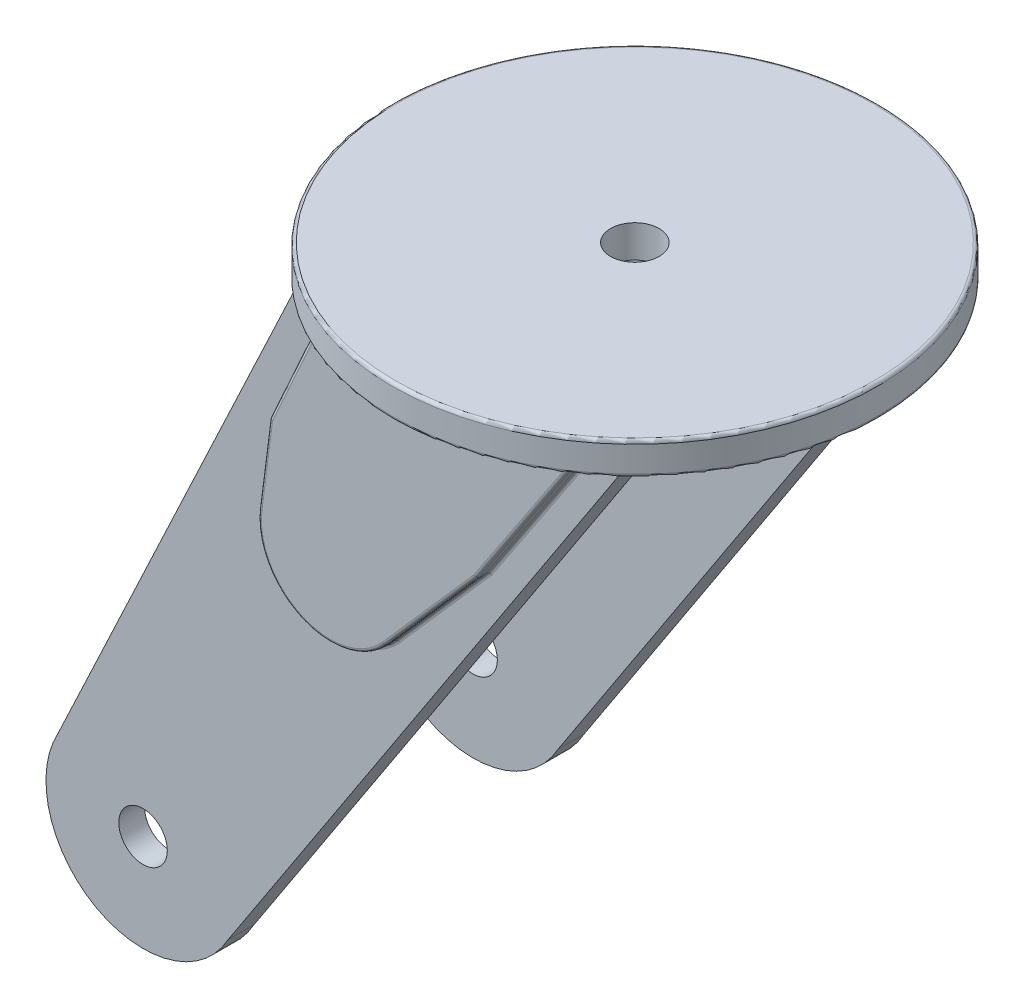
from build123d import *

# Parameters (mm, degrees)
SKETCH1_R            = 75
BOSS_EXTRUDE1_DEPTH  = 10
FILLET1_R            = 1
SKETCH2_R            = 7.5
BOSS_EXTRUDE2_DEPTH  = 8
BOSS_EXTRUDE3_DEPTH  = 4
FILLET2_R            = 1
CUT_EXTRUDE1_DEPTH   = 4
FILLET3_R            = 1
FILLET2_OF_MIRROR1_R = 1
FILLET3_OF_MIRROR1_R = 1
SKETCH7_R            = 7.5
CUT_EXTRUDE2_DEPTH   = 211


with BuildPart() as part:
    # Sketch1 → Boss-Extrude1 (new body)
    with BuildSketch(Plane(origin=(0, 0, 0), x_dir=(1, 0, 0), z_dir=(0, 1, 0))):
        Circle(SKETCH1_R)
    extrude(amount=BOSS_EXTRUDE1_DEPTH)

    # Fillet1
    fillet1_edges = [part.edges().sort_by_distance(p)[0] for p in [
        (-75, 0, 0),
        (-75, 10, 0),
    ]]
    fillet(fillet1_edges, radius=FILLET1_R)

    # Sketch2 → Boss-Extrude2 (add)
    with BuildSketch(Plane.XY.offset(47)):
        with BuildLine():
            Line((0, 0), (50, 0))
            Line((50, 0), (-70.747290118, -184.51878865))
            ThreePointArc((-70.747290118, -184.51878865), (-111.526989665, -196.248172723), (-123.243633002, -155.464810739))
            Line((-123.243633002, -155.464810739), (-50, 0))
            Line((-50, 0), (0, 0))
        make_face()
        with Locations((-97, -170)):
            Circle(SKETCH2_R, mode=Mode.SUBTRACT)
    boss_extrude2 = extrude(amount=BOSS_EXTRUDE2_DEPTH)

    # Sketch4 → Boss-Extrude3 (add)
    with BuildSketch(Plane.XY.offset(55)):
        with BuildLine():
            Line((40.265881009, 0), (10.01284637, -45.48041125))
            Line((10.01284637, -45.48041125), (-18.324907466, -77.700049173))
            ThreePointArc((-18.324907466, -77.700049173), (-44.281149675, -83.30242595), (-57.237348299, -60.123770847))
            Line((-57.237348299, -60.123770847), (-53.961723696, -34.496825425))
            Line((-53.961723696, -34.496825425), (-38.353470156, 0))
            Line((-38.353470156, 0), (40.265881009, 0))
        make_face()
    boss_extrude3 = extrude(amount=BOSS_EXTRUDE3_DEPTH)

    # Fillet2
    fillet2_edges = [part.edges().sort_by_distance(p)[0] for p in [
        (-46.157596926, -17.248412713, 55),
        (-55.599535997, -47.310298136, 55),
        (-44.281149675, -83.30242595, 55),
        (-4.156030548, -61.590230211, 55),
        (25.13936369, -22.740205625, 55),
        (-46.157596926, -17.248412713, 59),
        (-55.599535997, -47.310298136, 59),
        (-44.281149675, -83.30242595, 59),
        (-4.156030548, -61.590230211, 59),
        (25.13936369, -22.740205625, 59),
    ]]
    fillet(fillet2_edges, radius=FILLET2_R)

    # Sketch6 → Cut-Extrude1 (cut)
    with BuildSketch(Plane(origin=(0, 0, 47), x_dir=(-1, 0, 0), z_dir=(0, 0, -1))):
        with BuildLine():
            Line((-40.265881009, 0), (38.353470156, 0))
            Line((38.353470156, 0), (53.961723696, -34.496825425))
            Line((53.961723696, -34.496825425), (57.237348299, -60.123770847))
            ThreePointArc((57.237348299, -60.123770847), (44.281149675, -83.30242595), (18.324907466, -77.700049173))
            Line((18.324907466, -77.700049173), (-10.01284637, -45.48041125))
            Line((-10.01284637, -45.48041125), (-40.265881009, 0))
        make_face()
    cut_extrude1 = extrude(amount=-CUT_EXTRUDE1_DEPTH, mode=Mode.SUBTRACT)

    # Fillet3
    fillet3_edges = [part.edges().sort_by_distance(p)[0] for p in [
        (25.13936369, -22.740205625, 51),
        (-46.157596926, -17.248412713, 51),
        (-55.599535997, -47.310298136, 51),
        (-44.281149675, -83.30242595, 51),
        (-4.156030548, -61.590230211, 51),
        (25.13936369, -22.740205625, 47),
        (-4.156030548, -61.590230211, 47),
        (-44.281149675, -83.30242595, 47),
        (-55.599535997, -47.310298136, 47),
        (-46.157596926, -17.248412713, 47),
    ]]
    fillet(fillet3_edges, radius=FILLET3_R)

    # Mirror1: Boss-Extrude2, Boss-Extrude3, Cut-Extrude1 across plane
    add(boss_extrude2.mirror(Plane.XY))
    add(boss_extrude3.mirror(Plane.XY))
    add(cut_extrude1.mirror(Plane.XY), mode=Mode.SUBTRACT)

    # Fillet2 of Mirror1
    fillet2_of_mirror1_edges = [part.edges().sort_by_distance(p)[0] for p in [
        (-46.157596926, -17.248412713, -55),
        (-55.599535997, -47.310298136, -55),
        (-44.281149675, -83.30242595, -55),
        (-4.156030548, -61.590230211, -55),
        (25.13936369, -22.740205625, -55),
        (-46.157596926, -17.248412713, -59),
        (-55.599535997, -47.310298136, -59),
        (-44.281149675, -83.30242595, -59),
        (-4.156030548, -61.590230211, -59),
        (25.13936369, -22.740205625, -59),
    ]]
    fillet(fillet2_of_mirror1_edges, radius=FILLET2_OF_MIRROR1_R)

    # Fillet3 of Mirror1
    fillet3_of_mirror1_edges = [part.edges().sort_by_distance(p)[0] for p in [
        (25.13936369, -22.740205625, -51),
        (-46.157596926, -17.248412713, -51),
        (-55.599535997, -47.310298136, -51),
        (-44.281149675, -83.30242595, -51),
        (-4.156030548, -61.590230211, -51),
        (25.13936369, -22.740205625, -47),
        (-4.156030548, -61.590230211, -47),
        (-44.281149675, -83.30242595, -47),
        (-55.599535997, -47.310298136, -47),
        (-46.157596926, -17.248412713, -47),
    ]]
    fillet(fillet3_of_mirror1_edges, radius=FILLET3_OF_MIRROR1_R)

    # Sketch7 → Cut-Extrude2 (cut, through all)
    with BuildSketch(Plane(origin=(0, 10, 0), x_dir=(1, 0, 0), z_dir=(0, 1, 0))):
        Circle(SKETCH7_R)
    extrude(amount=-CUT_EXTRUDE2_DEPTH, mode=Mode.SUBTRACT)


solid = part.part
